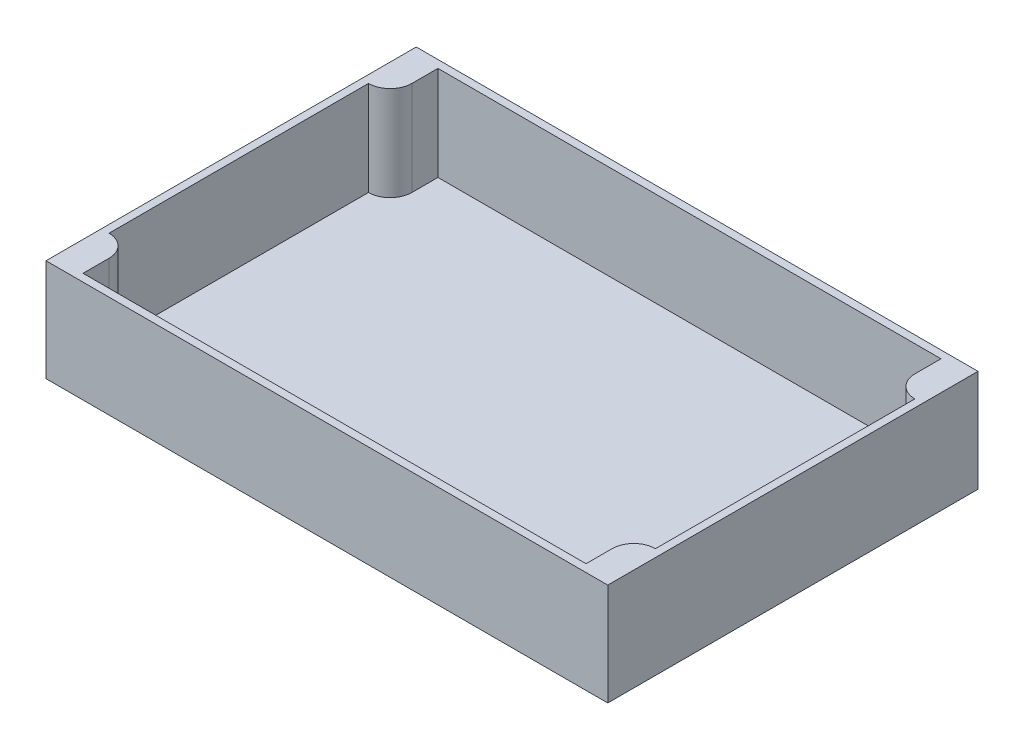
from build123d import *

# Parameters (mm, degrees)
SKETCH1_W           = 220
SKETCH1_H           = 145
BOSS_EXTRUDE1_DEPTH = 3
SKETCH2_W           = 220
SKETCH2_H           = 145
BOSS_EXTRUDE2_DEPTH = 37


with BuildPart() as part:
    # Sketch1 → Boss-Extrude1 (new body)
    with BuildSketch(Plane(origin=(0, 0, 0), x_dir=(1, 0, 0), z_dir=(0, 1, 0))):
        with Locations((110, 72.5)):
            Rectangle(SKETCH1_W, SKETCH1_H)
    extrude(amount=BOSS_EXTRUDE1_DEPTH)

    # Sketch2 → Boss-Extrude2 (add)
    with BuildSketch(Plane(origin=(0, 3, 0), x_dir=(1, 0, 0), z_dir=(0, 1, 0))):
        with Locations((110, 72.5)):
            Rectangle(SKETCH2_W, SKETCH2_H)
        with BuildLine():
            Line((3, 123.3), (3, 21.7))
            ThreePointArc((3, 21.7), (9.01040764, 19.21040764), (11.5, 13.2))
            Line((11.5, 13.2), (11.5, 3))
            Line((11.5, 3), (208.5, 3))
            Line((208.5, 3), (208.5, 13.2))
            ThreePointArc((208.5, 13.2), (210.98959236, 19.21040764), (217, 21.7))
            Line((217, 21.7), (217, 123.3))
            ThreePointArc((217, 123.3), (210.98959236, 125.78959236), (208.5, 131.8))
            Line((208.5, 131.8), (208.5, 142))
            Line((208.5, 142), (11.5, 142))
            Line((11.5, 142), (11.5, 131.8))
            ThreePointArc((11.5, 131.8), (9.01040764, 125.78959236), (3, 123.3))
        make_face(mode=Mode.SUBTRACT)
    extrude(amount=BOSS_EXTRUDE2_DEPTH)


solid = part.part
